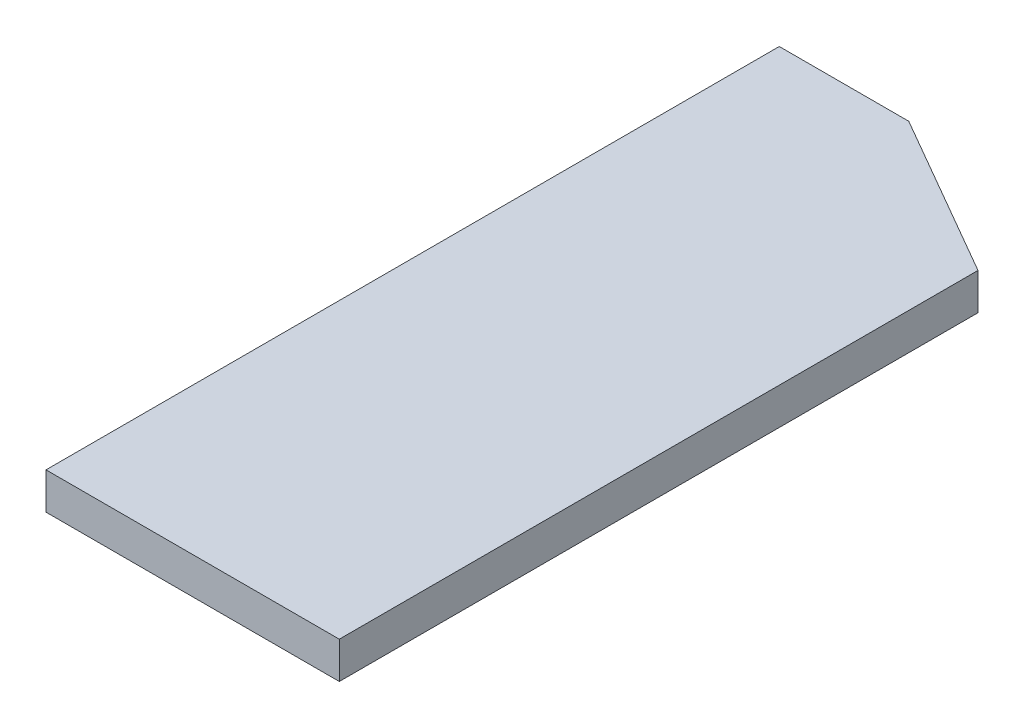
from build123d import *

# Parameters (mm, degrees)
EXTRUDE_1_DEPTH = 5


with BuildPart() as part:
    # Эскиз1 → Бобышка-Вытянуть1 (new body)
    with BuildSketch(Plane(origin=(0, 0, 0), x_dir=(1, 0, 0), z_dir=(0, 1, 0))):
        Polygon((0, 100), (17.661121371, 100), (40, 87.10264241), (40, 0), (0, 0), align=None)
    extrude(amount=EXTRUDE_1_DEPTH)


solid = part.part
